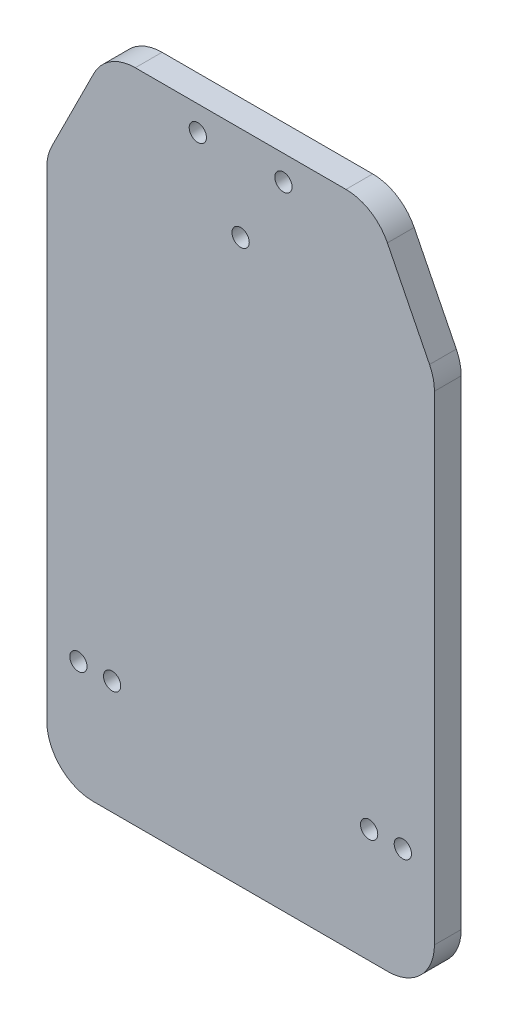
from build123d import *

# Parameters (mm, degrees)
BOSS_EXTRUDE1_DEPTH = 6.35
SKETCH2_R           = 2.05
CUT_EXTRUDE1_DEPTH  = 6.35


with BuildPart() as part:
    # Sketch1 → Boss-Extrude1 (new body)
    with BuildSketch(Plane.XY):
        with BuildLine():
            Line((55, 144.8), (30, 144.8))
            ThreePointArc((30, 144.8), (24.216957767, 143.157158892), (20.161300899, 138.71934955))
            Line((20.161300899, 138.71934955), (10.161300899, 118.71934955))
            ThreePointArc((10.161300899, 118.71934955), (9.294261116, 116.327282126), (9, 113.8))
            Line((9, 113.8), (9, 0))
            ThreePointArc((9, 0), (12.221825407, -7.778174593), (20, -11))
            Line((20, -11), (90, -11))
            ThreePointArc((90, -11), (97.778174593, -7.778174593), (101, 0))
            Line((101, 0), (101, 113.8))
            ThreePointArc((101, 113.8), (100.705738884, 116.327282126), (99.838699101, 118.71934955))
            Line((99.838699101, 118.71934955), (89.838699101, 138.71934955))
            ThreePointArc((89.838699101, 138.71934955), (85.783042233, 143.157158892), (80, 144.8))
            Line((80, 144.8), (55, 144.8))
        make_face()
    extrude(amount=BOSS_EXTRUDE1_DEPTH)

    # Sketch2 → Cut-Extrude1 (cut)
    with BuildSketch(Plane.XY.offset(6.35)):
        with Locations((16.5, 16)):
            Circle(SKETCH2_R)
        with Locations((24.5, 16)):
            Circle(SKETCH2_R)
        with Locations((85.5, 16)):
            Circle(SKETCH2_R)
        with Locations((93.5, 16)):
            Circle(SKETCH2_R)
        with Locations((44.84, 138.898469816)):
            Circle(SKETCH2_R)
        with Locations((55, 122.428157316)):
            Circle(SKETCH2_R)
        with Locations((65.16, 138.898469816)):
            Circle(SKETCH2_R)
    extrude(amount=-CUT_EXTRUDE1_DEPTH, mode=Mode.SUBTRACT)


solid = part.part
